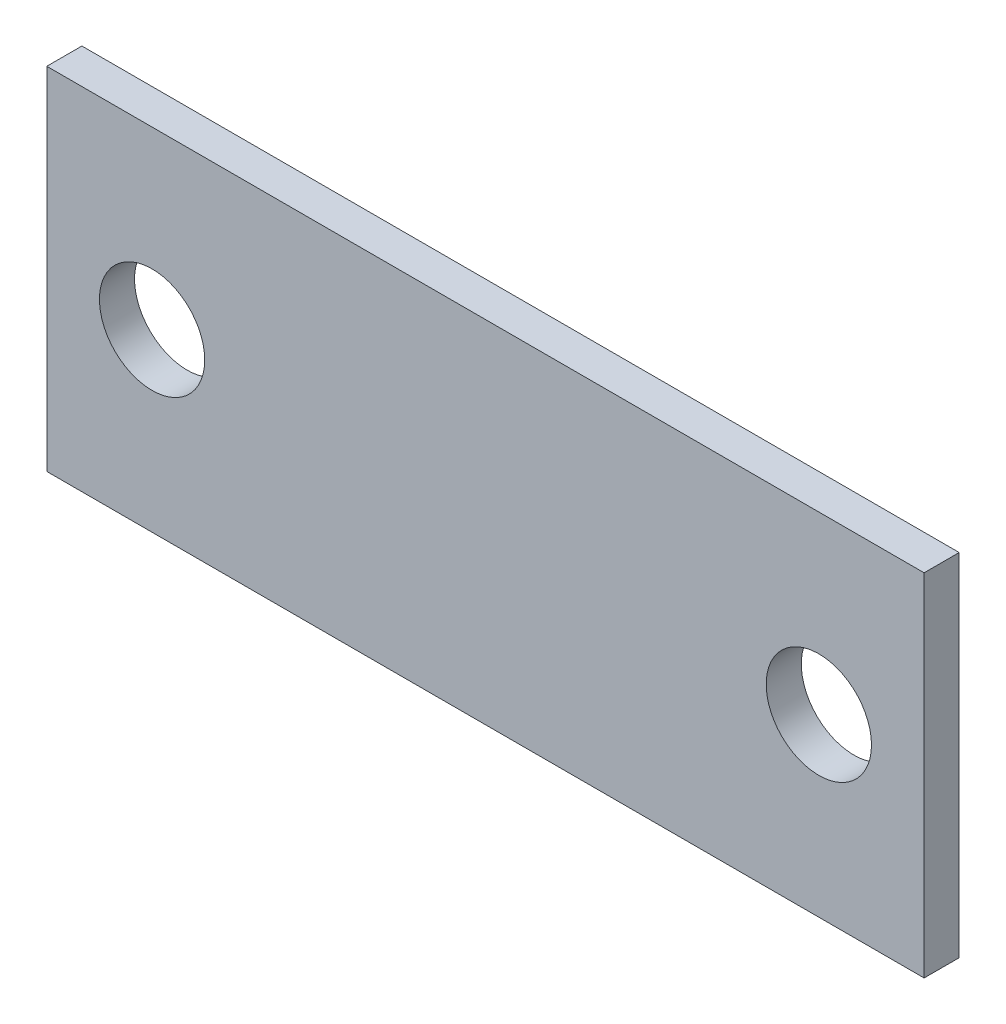
from build123d import *

# Parameters (mm, degrees)
SKETCH_1_W      = 250
SKETCH_1_H      = 100
SKETCH_1_R      = 15
EXTRUDE_1_DEPTH = 10


with BuildPart() as part:
    # Эскиз1 → Бобышка-Вытянуть1 (new body)
    with BuildSketch(Plane.XY):
        Rectangle(SKETCH_1_W, SKETCH_1_H)
        with Locations((-95, 0)):
            Circle(SKETCH_1_R, mode=Mode.SUBTRACT)
        with Locations((95, 0)):
            Circle(SKETCH_1_R, mode=Mode.SUBTRACT)
    extrude(amount=EXTRUDE_1_DEPTH)


solid = part.part
